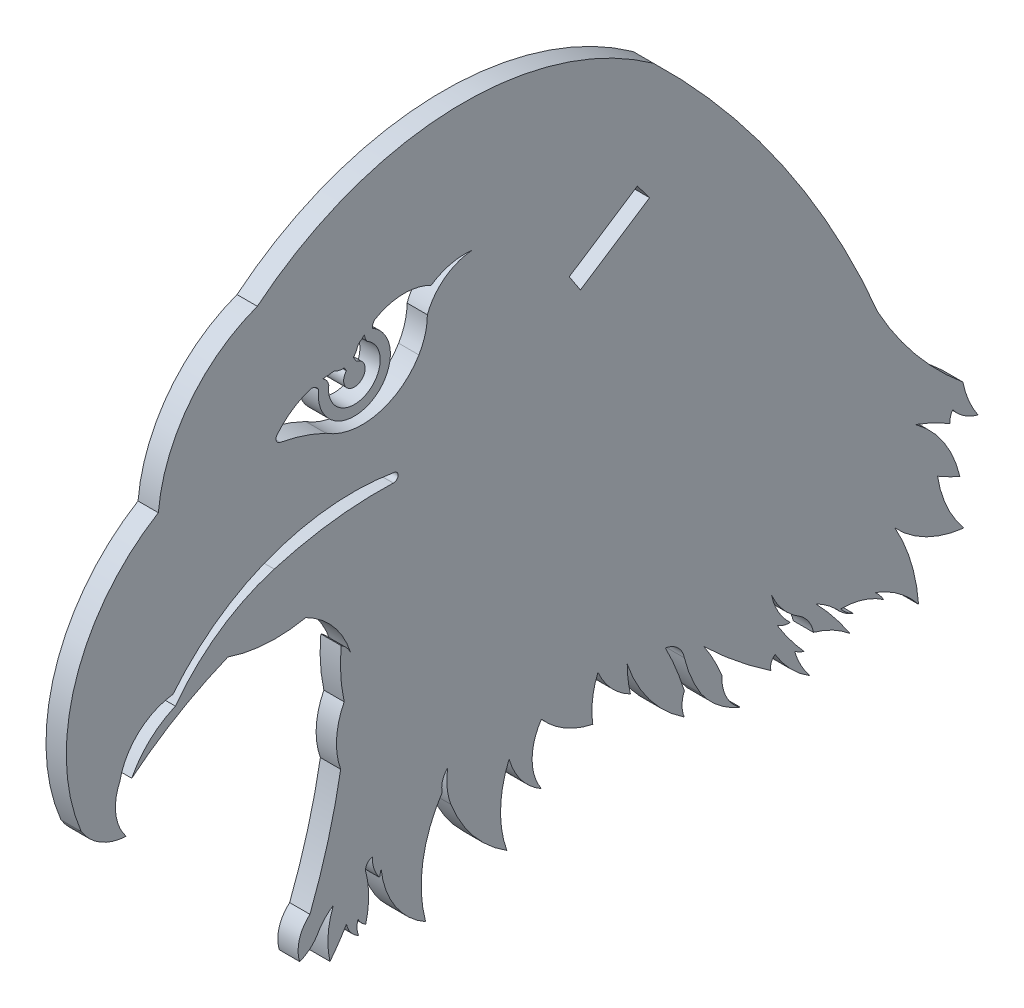
from build123d import *

# Parameters (mm, degrees)
BOSS_EXTRUDE1_DEPTH = 1.524


with BuildPart() as part:
    # Sketch1 → Boss-Extrude1 (new body)
    with BuildSketch(Plane(origin=(0, 0, 0), x_dir=(0, 0, -1), z_dir=(1, 0, 0))):
        with BuildLine():
            ThreePointArc((-39.766087672, 7.53819798), (-39.788385854, 9.159359689), (-39.376650536, 10.727523113))
            ThreePointArc((-39.376650536, 10.727523113), (-38.38712743, 9.198010472), (-36.938916025, 8.092909289))
            ThreePointArc((-36.938916025, 8.092909289), (-37.116600141, 9.11965252), (-37.180960586, 10.159667443))
            ThreePointArc((-37.180960586, 10.159667443), (-35.501518815, 7.005827133), (-32.889556647, 4.567613238))
            ThreePointArc((-32.889556647, 4.567613238), (-33.068250667, 5.419767026), (-32.889556647, 6.271920813))
            ThreePointArc((-32.889556647, 6.271920813), (-33.525332255, 8.054214348), (-34.31472645, 9.773992727))
            ThreePointArc((-34.31472645, 9.773992727), (-33.386978442, 9.325232377), (-32.889556647, 8.422639569))
            ThreePointArc((-32.889556647, 8.422639569), (-32.381030685, 6.888406354), (-31.634941588, 5.454592812))
            ThreePointArc((-31.634941588, 5.454592812), (-30.333229082, 4.068652702), (-28.690436857, 3.111302639))
            ThreePointArc((-28.690436857, 3.111302639), (-29.749458584, 4.317625817), (-30.073073861, 5.889890357))
            ThreePointArc((-30.073073861, 5.889890357), (-30.685861886, 7.189390524), (-31.42295526, 8.422639569))
            ThreePointArc((-31.42295526, 8.422639569), (-28.994492808, 6.271920813), (-26.38888902, 4.339603564))
            ThreePointArc((-26.38888902, 4.339603564), (-26.375894671, 4.836293549), (-26.077318991, 5.23343629))
            ThreePointArc((-26.077318991, 5.23343629), (-24.921769674, 3.718933706), (-23.437436471, 2.524878747))
            ThreePointArc((-23.437436471, 2.524878747), (-24.13962238, 3.552330638), (-24.613747179, 4.70295139))
            ThreePointArc((-24.613747179, 4.70295139), (-24.271951437, 4.495087879), (-23.903364681, 4.339603564))
            ThreePointArc((-23.903364681, 4.339603564), (-24.975158335, 5.652276906), (-25.929935588, 7.052367381))
            ThreePointArc((-25.929935588, 7.052367381), (-25.457764678, 6.820974643), (-24.937128221, 6.747315646))
            ThreePointArc((-24.937128221, 6.747315646), (-25.835396464, 7.873067204), (-26.343834751, 9.220543703))
            ThreePointArc((-26.343834751, 9.220543703), (-25.448809974, 7.81289845), (-24.165428581, 6.747315646))
            ThreePointArc((-24.165428581, 6.747315646), (-23.537897924, 6.08352246), (-23.203578284, 5.23343629))
            ThreePointArc((-23.203578284, 5.23343629), (-21.758332565, 4.657333504), (-20.463775992, 3.794342839))
            ThreePointArc((-20.463775992, 3.794342839), (-21.665968664, 5.454592812), (-23.021555735, 6.992149604))
            ThreePointArc((-23.021555735, 6.992149604), (-22.211227264, 6.501645882), (-21.488052798, 5.889890357))
            ThreePointArc((-21.488052798, 5.889890357), (-20.906294433, 5.349520602), (-20.208697963, 4.970309009))
            ThreePointArc((-20.208697963, 4.970309009), (-20.73073103, 5.303077466), (-21.171693336, 5.737595144))
            ThreePointArc((-21.171693336, 5.737595144), (-19.458680025, 5.477835333), (-17.905098233, 4.710845516))
            ThreePointArc((-17.905098233, 4.710845516), (-18.209539479, 5.130223244), (-18.563856779, 5.508404949))
            ThreePointArc((-18.563856779, 5.508404949), (-16.773848011, 4.531909647), (-15.311127876, 3.111302639))
            ThreePointArc((-15.311127876, 3.111302639), (-15.87396522, 6.131805672), (-17.0835312, 8.956194914))
            ThreePointArc((-17.0835312, 8.956194914), (-14.724560118, 7.201947997), (-11.904598072, 6.371321199))
            ThreePointArc((-11.904598072, 6.371321199), (-13.194884564, 8.412792812), (-13.883701821, 10.727523113))
            ThreePointArc((-13.883701821, 10.727523113), (-13.063612384, 10.276206064), (-12.21435048, 9.882520933))
            ThreePointArc((-12.21435048, 9.882520933), (-13.41978747, 12.697740989), (-15.535895042, 14.911477885))
            ThreePointArc((-15.535895042, 14.911477885), (-14.209521747, 14.348770638), (-12.937200298, 13.672676198))
            ThreePointArc((-12.937200298, 13.672676198), (-12.921537146, 14.091835911), (-12.744938548, 14.472300278))
            ThreePointArc((-12.744938548, 14.472300278), (-11.904598072, 13.672676198), (-10.84978702, 13.19003303))
            ThreePointArc((-10.84978702, 13.19003303), (-11.553781904, 14.488471198), (-11.985938543, 15.90084194))
            ThreePointArc((-11.985938543, 15.90084194), (-15.535895042, 19.465627273), (-18.362734761, 23.627221056))
            ThreePointArc((-18.362734761, 23.627221056), (-25.543749627, 36.780772404), (-35.2097377, 48.232914656))
            ThreePointArc((-35.2097377, 48.232914656), (-50.234867498, 52.792366992), (-64.945536929, 47.302436579))
            ThreePointArc((-64.945536929, 47.302436579), (-70.067059923, 43.527092995), (-72.375055911, 37.597812139))
            ThreePointArc((-72.375055911, 37.597812139), (-78.585415112, 29.759489009), (-78.162667801, 19.76803488))
            ThreePointArc((-78.162667801, 19.76803488), (-76.720136049, 18.354135791), (-74.786560866, 17.769930775))
            ThreePointArc((-74.786560866, 17.769930775), (-75.567073, 19.596038641), (-75.268861856, 21.55943856))
            ThreePointArc((-75.268861856, 21.55943856), (-73.866409557, 24.045459001), (-71.277028566, 25.246407031))
            ThreePointArc((-71.277028566, 25.246407031), (-67.018990287, 29.010880259), (-61.763652433, 31.175036612))
            ThreePointArc((-61.763652433, 31.175036612), (-58.204428111, 31.622213036), (-54.626779193, 31.360540069))
            ThreePointArc((-54.626779193, 31.360540069), (-54.38391526, 30.982349818), (-54.74010193, 30.708229749))
            ThreePointArc((-54.74010193, 30.708229749), (-59.253910145, 30.508178317), (-63.676568488, 29.583744244))
            ThreePointArc((-63.676568488, 29.583744244), (-67.810853792, 27.591260252), (-71.094682727, 24.385207388))
            ThreePointArc((-71.094682727, 24.385207388), (-73.001174368, 23.147648302), (-74.372813581, 21.335227617))
            ThreePointArc((-74.372813581, 21.335227617), (-70.921038347, 23.730523361), (-67.161221743, 25.605616175))
            ThreePointArc((-67.161221743, 25.605616175), (-64.258019855, 25.033393709), (-61.306639656, 25.246407031))
            ThreePointArc((-61.306639656, 25.246407031), (-59.239675084, 23.627221056), (-57.958709884, 21.335227617))
            ThreePointArc((-57.958709884, 21.335227617), (-58.253628213, 21.765830279), (-58.655738988, 22.09854998))
            ThreePointArc((-58.655738988, 22.09854998), (-58.687960168, 20.205629212), (-58.426523154, 18.330572434))
            ThreePointArc((-58.426523154, 18.330572434), (-58.997624773, 16.230123876), (-58.687960168, 14.075559178))
            ThreePointArc((-58.687960168, 14.075559178), (-59.639756178, 9.882520933), (-60.995201938, 5.802048883))
            ThreePointArc((-60.995201938, 5.802048883), (-61.785840084, 4.572743262), (-61.763652433, 3.111302639))
            ThreePointArc((-61.763652433, 3.111302639), (-61.011303008, 3.548377805), (-60.437577266, 4.202520855))
            ThreePointArc((-60.437577266, 4.202520855), (-59.921186541, 4.931196455), (-59.239675084, 5.508404949))
            ThreePointArc((-59.239675084, 5.508404949), (-59.634882036, 3.765849198), (-59.490750384, 1.98486207))
            ThreePointArc((-59.490750384, 1.98486207), (-58.839540085, 2.867280546), (-58.253628213, 3.794342839))
            ThreePointArc((-58.253628213, 3.794342839), (-57.931749389, 3.08851925), (-57.332513682, 2.595863706))
            ThreePointArc((-57.332513682, 2.595863706), (-57.462343622, 3.128706124), (-57.388264962, 3.672111321))
            ThreePointArc((-57.388264962, 3.672111321), (-57.143363454, 3.324813541), (-56.812604611, 3.057996966))
            ThreePointArc((-56.812604611, 3.057996966), (-56.586872806, 4.779821424), (-56.812604611, 6.501645882))
            ThreePointArc((-56.812604611, 6.501645882), (-56.703634739, 6.946501732), (-56.318894911, 7.194990013))
            ThreePointArc((-56.318894911, 7.194990013), (-56.182996746, 6.339059761), (-55.763022206, 5.580965905))
            ThreePointArc((-55.763022206, 5.580965905), (-55.717634243, 5.834168879), (-55.654431363, 6.08352246))
            ThreePointArc((-55.654431363, 6.08352246), (-54.597676884, 3.128483383), (-52.312285394, 0.97767616))
            ThreePointArc((-52.312285394, 0.97767616), (-52.521764903, 5.00547988), (-51.066879633, 8.767180735))
            ThreePointArc((-51.066879633, 8.767180735), (-51.04092459, 9.517465501), (-50.652109005, 10.159667443))
            ThreePointArc((-50.652109005, 10.159667443), (-50.701659084, 8.889713032), (-50.410373806, 7.652622776))
            ThreePointArc((-50.410373806, 7.652622776), (-48.72631463, 4.764541921), (-46.212474989, 2.560528176))
            ThreePointArc((-46.212474989, 2.560528176), (-46.687287623, 5.507535187), (-46.045054172, 8.422639569))
            ThreePointArc((-46.045054172, 8.422639569), (-45.142673796, 6.61111454), (-43.618270689, 5.279908906))
            ThreePointArc((-43.618270689, 5.279908906), (-44.31861886, 7.53819798), (-43.618270689, 9.796487055))
            ThreePointArc((-43.618270689, 9.796487055), (-41.87693138, 8.352192746), (-39.766087672, 7.53819798))
        make_face()
        with BuildLine():
            Line((-57.506840911, 40.009329894), (-57.736016266, 40.371627439))
            ThreePointArc((-57.736016266, 40.371627439), (-57.588728658, 40.557064299), (-57.483137019, 40.769033339))
            ThreePointArc((-57.483137019, 40.769033339), (-57.348770196, 41.045580651), (-57.107382269, 41.236013652))
            ThreePointArc((-57.107382269, 41.236013652), (-57.002433177, 41.345778867), (-56.893709505, 41.451806587))
            ThreePointArc((-56.893709505, 41.451806587), (-56.841458113, 41.159748597), (-56.697137431, 40.900519705))
            ThreePointArc((-56.697137431, 40.900519705), (-56.803128533, 37.476374088), (-59.581758638, 39.480175991))
            ThreePointArc((-59.581758638, 39.480175991), (-59.733142968, 39.855223564), (-60.038444642, 40.12049472))
            ThreePointArc((-60.038444642, 40.12049472), (-59.792610208, 40.145465283), (-59.545869269, 40.158769658))
            ThreePointArc((-59.545869269, 40.158769658), (-59.336377437, 40.199912373), (-59.123152104, 40.189211537))
            ThreePointArc((-59.123152104, 40.189211537), (-58.787034274, 40.057394259), (-58.426523154, 40.037830946))
            Line((-58.426523154, 40.037830946), (-58.253378123, 39.764110329))
            ThreePointArc((-58.253378123, 39.764110329), (-57.408034955, 38.449554092), (-57.506840911, 40.009329894))
        make_face(mode=Mode.SUBTRACT)
        Polygon((-40.697243628, 36.240839783), (-41.530413405, 37.51692917), (-36.418811659, 40.854338077), (-35.498261528, 39.635300078), align=None, mode=Mode.SUBTRACT)
        with BuildLine():
            ThreePointArc((-56.318894911, 41.562015432), (-56.466522863, 36.792750929), (-60.336691776, 39.583713217))
            ThreePointArc((-60.336691776, 39.583713217), (-60.564183296, 39.827883968), (-60.876937281, 39.944317177))
            ThreePointArc((-60.876937281, 39.944317177), (-62.298643167, 39.274184779), (-63.456306467, 38.211103999))
            ThreePointArc((-63.456306467, 38.211103999), (-63.516421667, 37.839777188), (-63.228410638, 37.597812139))
            ThreePointArc((-63.228410638, 37.597812139), (-61.479460706, 37.153430546), (-59.80470892, 36.481487599))
            ThreePointArc((-59.80470892, 36.481487599), (-55.9703369, 35.788633112), (-52.81580705, 38.075857969))
            ThreePointArc((-52.81580705, 38.075857969), (-52.342385387, 39.180576563), (-52.18202143, 40.371716623))
            ThreePointArc((-52.18202143, 40.371716623), (-50.880435467, 42.111744698), (-48.848806307, 42.882657583))
            ThreePointArc((-48.848806307, 42.882657583), (-50.445448296, 42.792507069), (-51.90451872, 42.137903177))
            ThreePointArc((-51.90451872, 42.137903177), (-54.040720374, 42.630872743), (-56.1454441, 42.017264938))
            ThreePointArc((-56.1454441, 42.017264938), (-56.278108465, 41.807143004), (-56.318894911, 41.562015432))
        make_face(mode=Mode.SUBTRACT)
    extrude(amount=BOSS_EXTRUDE1_DEPTH)


solid = part.part
